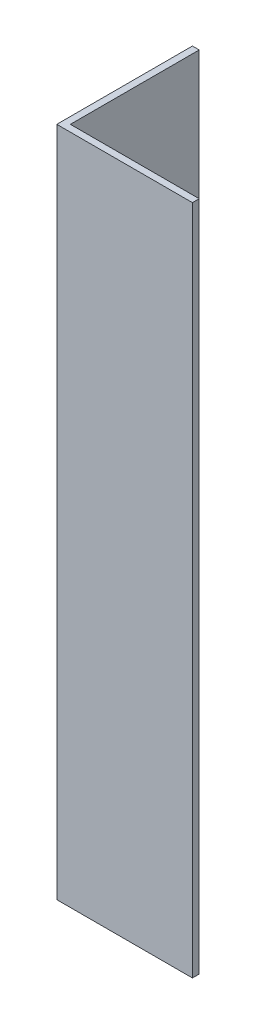
from build123d import *

# Parameters (mm, degrees)
EXTRUDE_1_DEPTH = 99


with BuildPart() as part:
    # Эскиз1 → Бобышка-Вытянуть1 (new body)
    with BuildSketch(Plane(origin=(0, 0, 0), x_dir=(1, 0, 0), z_dir=(0, 1, 0))):
        Polygon((0, 0), (0, 20), (1, 20), (1, 1), (20, 1), (20, 0), align=None)
    extrude(amount=EXTRUDE_1_DEPTH)


solid = part.part
